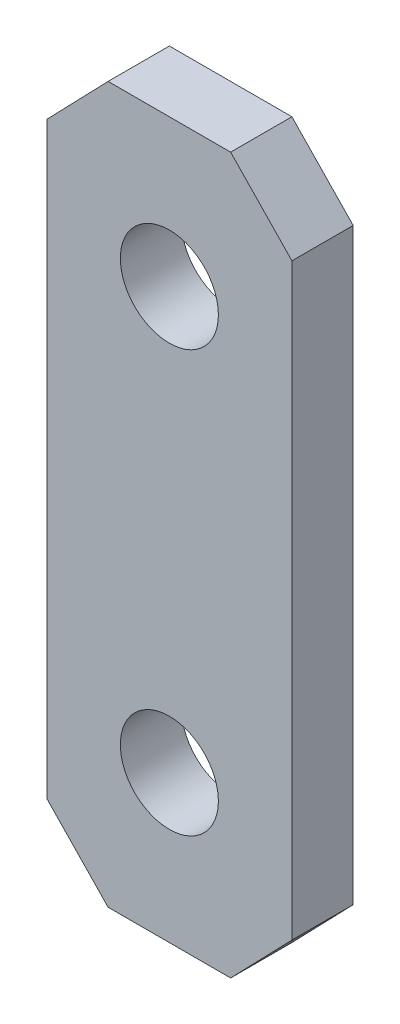
from build123d import *

# Parameters (mm, degrees)
SKETCH4_R           = 2.54
BOSS_EXTRUDE1_DEPTH = 3.175


with BuildPart() as part:
    # Sketch4 → Boss-Extrude1 (new body)
    with BuildSketch(Plane.XY):
        Polygon((0, 0), (12.7, 0), (12.7, 15.24), (9.525, 18.529765797), (3.175, 18.529765797), (0, 15.24), align=None)
        with Locations((6.35, 10.909765797)):
            Circle(SKETCH4_R, mode=Mode.SUBTRACT)
    boss_extrude1 = extrude(amount=BOSS_EXTRUDE1_DEPTH)

    # Mirror1: Boss-Extrude1 across plane
    add(boss_extrude1.mirror(Plane.ZX))


solid = part.part
